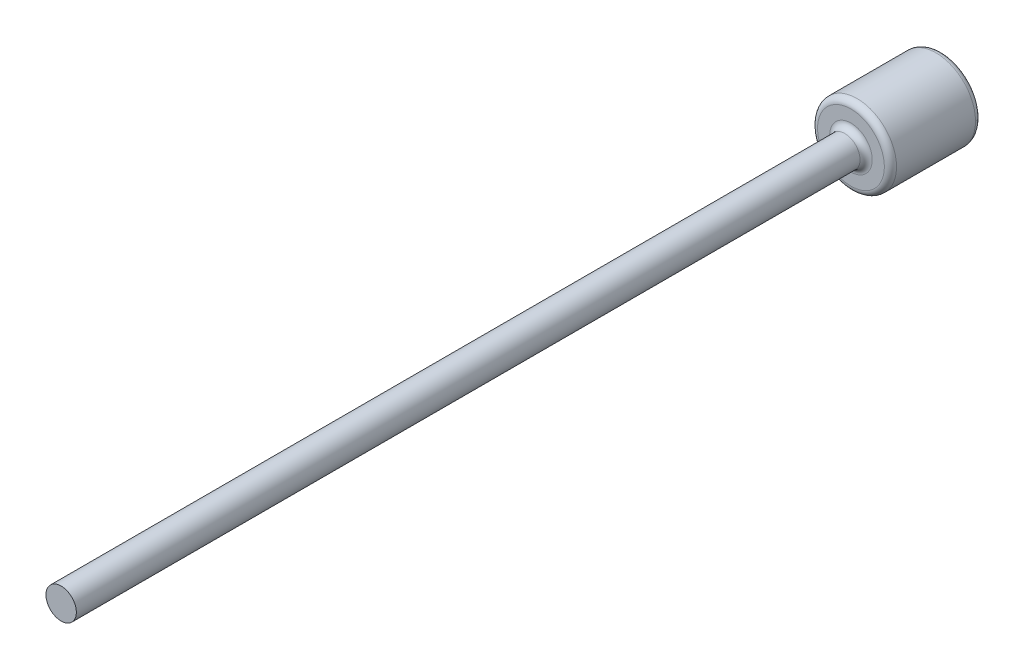
from build123d import *

# Parameters (mm, degrees)
SKETCH1_R           = 13
BOSS_EXTRUDE1_DEPTH = 30
SKETCH2_R           = 5
BOSS_EXTRUDE2_DEPTH = 240
SKETCH3_R           = 5
BOSS_EXTRUDE3_DEPTH = 20
FILLET1_R           = 2


with BuildPart() as part:
    # Sketch1 → Boss-Extrude1 (new body)
    with BuildSketch(Plane.XY):
        Circle(SKETCH1_R)
    extrude(amount=-BOSS_EXTRUDE1_DEPTH)

    # Sketch2 → Boss-Extrude2 (add)
    with BuildSketch(Plane.XY):
        Circle(SKETCH2_R)
    extrude(amount=BOSS_EXTRUDE2_DEPTH)

    # Sketch3 → Boss-Extrude3 (add)
    with BuildSketch(Plane.XY.offset(240)):
        Circle(SKETCH3_R)
    extrude(amount=BOSS_EXTRUDE3_DEPTH)

    # Fillet1
    fillet1_edges = [part.edges().sort_by_distance(p)[0] for p in [
        (-13, 0, 0),
        (-13, 0, -30),
        (-5, 0, 0),
    ]]
    fillet(fillet1_edges, radius=FILLET1_R)


solid = part.part
